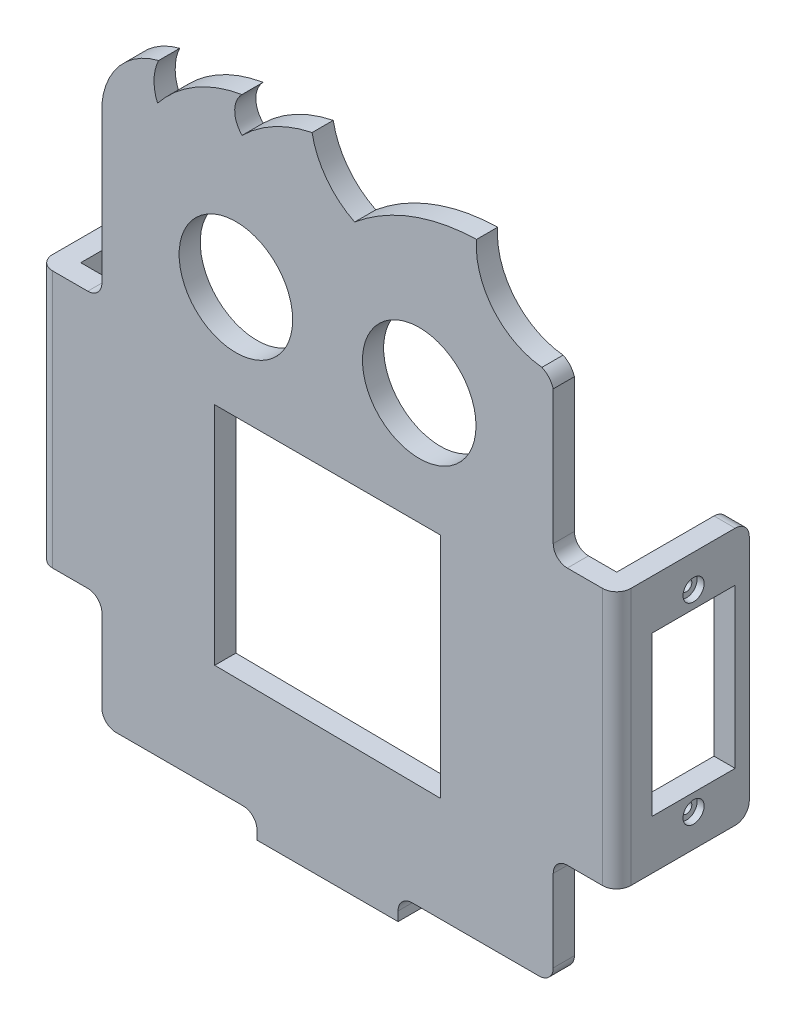
from build123d import *

# Parameters (mm, degrees)
MODEL_R                  = 8.05
SALIENTE_EXTRUIR1_DEPTH  = 3
CROQUIS2_W               = 3
CROQUIS2_H               = 36.5
SALIENTE_EXTRUIR2_DEPTH  = 15.8
CROQUIS3_R               = 0.75
CROQUIS3_W               = 11.8
CROQUIS3_H               = 22.5
CORTAR_EXTRUIR1_DEPTH    = 3
REDONDEO1_R              = 2
CROQUIS5_R               = 1.5
CORTAR_EXTRUIR3_DEPTH    = 1
REDONDEO1_OF_SIMETR_A1_R = 2
REDONDEO2_R              = 2
CROQUIS6_W               = 20
CROQUIS6_H               = 3
SALIENTE_EXTRUIR3_DEPTH  = 8
CROQUIS7_R               = 1.5
CORTAR_EXTRUIR4_DEPTH    = 3
CROQUIS8_R               = 2.25
CORTAR_EXTRUIR5_DEPTH    = 1
REDONDEO3_R              = 2


with BuildPart() as part:
    # Model → Saliente-Extruir1 (new body)
    with BuildSketch(Plane.XY):
        with BuildLine():
            Line((117.128163256, -122.351547449), (137.128163256, -122.351547449))
            Line((137.128163256, -122.351547449), (137.128163256, -121.037289507))
            ThreePointArc((137.128163256, -121.037289507), (137.713949693, -119.623075945), (139.128163256, -119.037289507))
            Line((139.128163256, -119.037289507), (157.128163256, -119.037289507))
            ThreePointArc((157.128163256, -119.037289507), (158.542376818, -118.45150307), (159.128163256, -117.037289507))
            Line((159.128163256, -117.037289507), (159.128163256, -105.429203673))
            ThreePointArc((159.128163256, -105.429203673), (159.713949693, -104.014990111), (161.128163256, -103.429203673))
            Line((161.128163256, -103.429203673), (168.128163256, -103.429203673))
            Line((168.128163256, -103.429203673), (168.128163256, -66.929203673))
            Line((168.128163256, -66.929203673), (161.128163256, -66.929203673))
            ThreePointArc((161.128163256, -66.929203673), (159.713949693, -66.343417236), (159.128163256, -64.929203673))
            Line((159.128163256, -64.929203673), (159.128163256, -45.925126076))
            ThreePointArc((159.128163256, -45.925126076), (158.525375774, -44.832630562), (157.530270287, -44.079859504))
            ThreePointArc((157.530270287, -44.079859504), (150.626254462, -40.441158757), (148.250928406, -33.007222803))
            ThreePointArc((148.250928406, -33.007222803), (139.057304014, -34.79177863), (130.970368491, -39.515002403))
            ThreePointArc((130.970368491, -39.515002403), (127.01096078, -36.241427472), (124.933546078, -31.542752084))
            ThreePointArc((124.933546078, -31.542752084), (119.585499261, -33.477559346), (115.007991873, -36.852690455))
            ThreePointArc((115.007991873, -36.852690455), (113.960942039, -34.357491642), (114.984938003, -31.852743603))
            ThreePointArc((114.984938003, -31.852743603), (108.346137898, -34.269313364), (103.017340976, -38.907998482))
            ThreePointArc((103.017340976, -38.907998482), (102.522640368, -36.230932008), (103.164365263, -33.585255769))
            ThreePointArc((103.164365263, -33.585255769), (97.657864433, -36.973852922), (95.128163256, -42.924042331))
            Line((95.128163256, -42.924042331), (95.128163256, -64.929203673))
            ThreePointArc((95.128163256, -64.929203673), (94.542376818, -66.343417236), (93.128163256, -66.929203673))
            Line((93.128163256, -66.929203673), (86.128163256, -66.929203673))
            Line((86.128163256, -66.929203673), (86.128163256, -103.429203673))
            Line((86.128163256, -103.429203673), (93.128163256, -103.429203673))
            ThreePointArc((93.128163256, -103.429203673), (94.542376818, -104.014990111), (95.128163256, -105.429203673))
            Line((95.128163256, -105.429203673), (95.128163256, -117.046472124))
            ThreePointArc((95.128163256, -117.046472124), (95.687839985, -118.507520387), (97.128163256, -119.118559619))
            Line((97.128163256, -119.118559619), (115.128163256, -119.118559619))
            ThreePointArc((115.128163256, -119.118559619), (116.542376818, -119.704346056), (117.128163256, -121.118559619))
            Line((117.128163256, -121.118559619), (117.128163256, -122.351547449))
        make_face()
        with Locations((114.128163256, -55.929203673)):
            Circle(MODEL_R, mode=Mode.SUBTRACT)
        with Locations((140.128163256, -55.929203673)):
            Circle(MODEL_R, mode=Mode.SUBTRACT)
        Polygon((143.127299166, -104.206170984), (143.127299166, -71.873604522), (111.129027345, -71.873604522), (111.129027345, -103.873604522), align=None, mode=Mode.SUBTRACT)
    extrude(amount=SALIENTE_EXTRUIR1_DEPTH)

    # Croquis2 → Saliente-Extruir2 (add)
    with BuildSketch(Plane(origin=(0, 0, 0), x_dir=(-1, 0, 0), z_dir=(0, 0, -1))):
        with Locations((-166.628163256, -85.179203673)):
            Rectangle(CROQUIS2_W, CROQUIS2_H)
    saliente_extruir2 = extrude(amount=SALIENTE_EXTRUIR2_DEPTH)

    # Croquis3 → Cortar-Extruir1 (cut)
    with BuildSketch(Plane(origin=(168.128163256, 0, 0), x_dir=(0, 0, -1), z_dir=(1, 0, 0))):
        with Locations((7.9, -98.829203673)):
            Circle(CROQUIS3_R)
        with Locations((7.9, -71.529203673)):
            Circle(CROQUIS3_R)
        with Locations((7.9, -85.179203673)):
            Rectangle(CROQUIS3_W, CROQUIS3_H)
    cortar_extruir1 = extrude(amount=-CORTAR_EXTRUIR1_DEPTH, mode=Mode.SUBTRACT)

    # Redondeo1
    redondeo1_edges = [part.edges().sort_by_distance(p)[0] for p in [
        (166.628163256, -103.429203673, -15.8),
        (166.628163256, -66.929203673, -15.8),
    ]]
    fillet(redondeo1_edges, radius=REDONDEO1_R)

    # Croquis5 → Cortar-Extruir3 (cut)
    with BuildSketch(Plane(origin=(168.128163256, 0, 0), x_dir=(0, 0, -1), z_dir=(1, 0, 0))):
        with Locations((7.9, -71.529203673)):
            Circle(CROQUIS5_R)
        with Locations((7.9, -98.829203673)):
            Circle(CROQUIS5_R)
    cortar_extruir3 = extrude(amount=-CORTAR_EXTRUIR3_DEPTH, mode=Mode.SUBTRACT)

    # Simetría1: Saliente-Extruir2, Cortar-Extruir1, Cortar-Extruir3 across plane
    add(saliente_extruir2.mirror(Plane(origin=(127.128163256, 0, 0), x_dir=(0, 0, 1), z_dir=(1, 0, 0))))
    add(cortar_extruir1.mirror(Plane(origin=(127.128163256, 0, 0), x_dir=(0, 0, 1), z_dir=(1, 0, 0))), mode=Mode.SUBTRACT)
    add(cortar_extruir3.mirror(Plane(origin=(127.128163256, 0, 0), x_dir=(0, 0, 1), z_dir=(1, 0, 0))), mode=Mode.SUBTRACT)

    # Redondeo1 of Simetría1
    redondeo1_of_simetr_a1_edges = [part.edges().sort_by_distance(p)[0] for p in [
        (87.628163256, -103.429203673, -15.8),
        (87.628163256, -66.929203673, -15.8),
    ]]
    fillet(redondeo1_of_simetr_a1_edges, radius=REDONDEO1_OF_SIMETR_A1_R)

    # Redondeo2
    redondeo2_edges = [part.edges().sort_by_distance(p)[0] for p in [
        (168.128163256, -85.179203673, 3),
        (86.128163256, -85.179203673, 3),
    ]]
    fillet(redondeo2_edges, radius=REDONDEO2_R)

    # Croquis6 → Saliente-Extruir3 (add)
    with BuildSketch(Plane(origin=(0, 0, 0), x_dir=(-1, 0, 0), z_dir=(0, 0, -1))):
        with Locations((-127.128163256, -120.851547449)):
            Rectangle(CROQUIS6_W, CROQUIS6_H)
    extrude(amount=SALIENTE_EXTRUIR3_DEPTH)

    # Croquis7 → Cortar-Extruir4 (cut)
    with BuildSketch(Plane(origin=(0, -119.351547449, 0), x_dir=(1, 0, 0), z_dir=(0, 1, 0))):
        with Locations((133.128163256, 3.5)):
            Circle(CROQUIS7_R)
        with Locations((121.128163256, 3.5)):
            Circle(CROQUIS7_R)
    extrude(amount=-CORTAR_EXTRUIR4_DEPTH, mode=Mode.SUBTRACT)

    # Croquis8 → Cortar-Extruir5 (cut)
    with BuildSketch(Plane(origin=(0, -119.351547449, 0), x_dir=(1, 0, 0), z_dir=(0, 1, 0))):
        with Locations((133.128163256, 3.5)):
            Circle(CROQUIS8_R)
        with Locations((121.128163256, 3.5)):
            Circle(CROQUIS8_R)
    extrude(amount=-CORTAR_EXTRUIR5_DEPTH, mode=Mode.SUBTRACT)

    # Redondeo3
    redondeo3_edges = [part.edges().sort_by_distance(p)[0] for p in [
        (117.128163256, -120.851547449, -8),
        (137.128163256, -120.851547449, -8),
    ]]
    fillet(redondeo3_edges, radius=REDONDEO3_R)


solid = part.part
